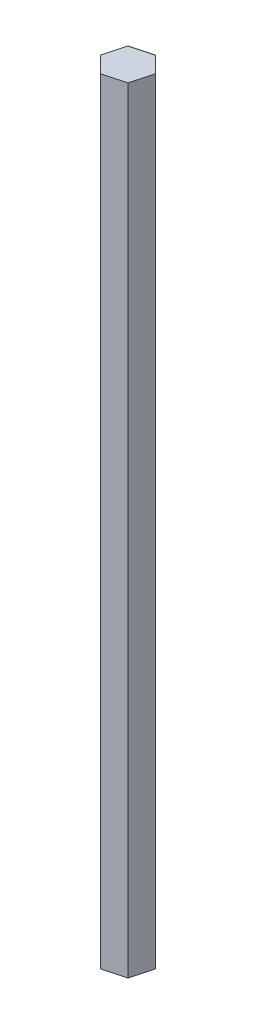
from build123d import *

# Parameters (mm, degrees)
BOSS_EXTRUDE1_DEPTH = 252.476


with BuildPart() as part:
    # Sketch1 → Boss-Extrude1 (new body)
    with BuildSketch(Plane(origin=(0, 0, 0), x_dir=(1, 0, 0), z_dir=(0, 1, 0))):
        Polygon((5.20854855, -5.20854855), (7.115009636, 1.906461086), (1.906461086, 7.115009636), (-5.20854855, 5.20854855), (-7.115009636, -1.906461086), (-1.906461086, -7.115009636), align=None)
    extrude(amount=BOSS_EXTRUDE1_DEPTH)


solid = part.part
